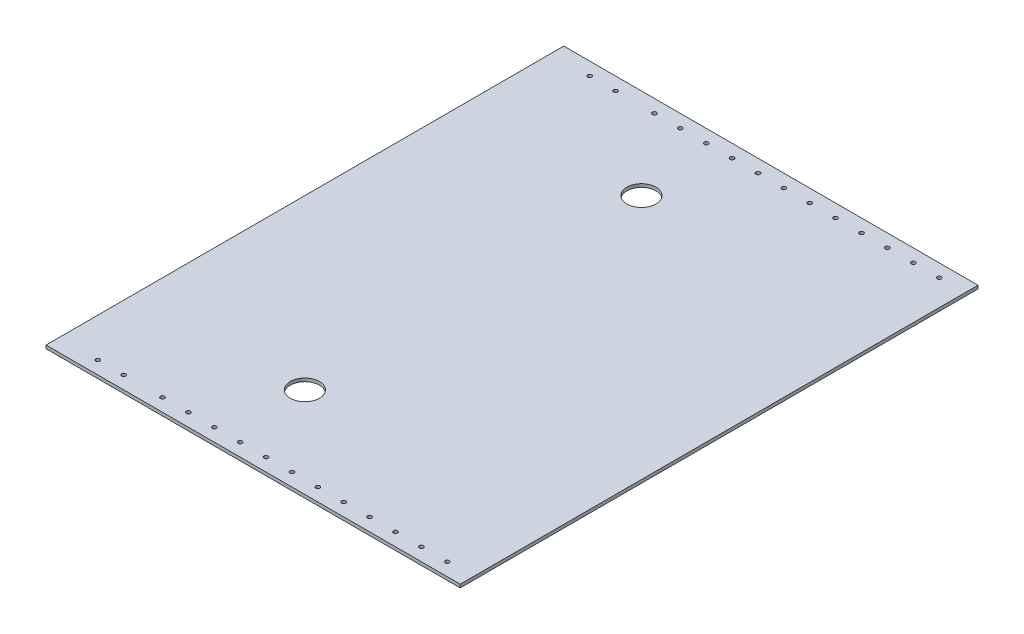
from build123d import *

# Parameters (mm, degrees)
SKETCH1_W               = 571.5
SKETCH1_H               = 508
BOSS_EXTRUDE1_DEPTH     = 3.175
SKETCH2_R               = 14.2875
CUT_EXTRUDE1_DEPTH      = 3.175
SKETCH4_R               = 2.0193
CUT_EXTRUDE3_DEPTH      = 1
CUT_EXTRUDE3_DEPTH_BACK = 4.175
SKETCH5_W               = 619.579537293
SKETCH5_H               = 89.035098343
CUT_EXTRUDE4_DEPTH      = 165.1


with BuildPart() as part:
    # Sketch1 → Boss-Extrude1 (new body)
    with BuildSketch(Plane(origin=(0, 0, 0), x_dir=(1, 0, 0), z_dir=(0, 1, 0))):
        with Locations((285.75, 254)):
            Rectangle(SKETCH1_W, SKETCH1_H)
    extrude(amount=BOSS_EXTRUDE1_DEPTH)

    # Sketch2 → Cut-Extrude1 (cut)
    with BuildSketch(Plane(origin=(0, 3.175, 0), x_dir=(1, 0, 0), z_dir=(0, 1, 0))):
        with Locations((330.2, 419.1)):
            Circle(SKETCH2_R)
        with Locations((330.2, 88.9)):
            Circle(SKETCH2_R)
    extrude(amount=-CUT_EXTRUDE1_DEPTH, mode=Mode.SUBTRACT)

    # Sketch4 → Cut-Extrude3 (cut, two sides)
    with BuildSketch(Plane(origin=(0, 3.175, 0), x_dir=(1, 0, 0), z_dir=(0, 1, 0))) as cut_extrude3_sk:
        with Locations((546.1, 495.3)):
            Circle(SKETCH4_R)
        with Locations((520.7, 495.3)):
            Circle(SKETCH4_R)
        with Locations((495.3, 495.3)):
            Circle(SKETCH4_R)
        with Locations((469.9, 495.3)):
            Circle(SKETCH4_R)
        with Locations((444.5, 495.3)):
            Circle(SKETCH4_R)
        with Locations((419.1, 495.3)):
            Circle(SKETCH4_R)
        with Locations((393.7, 495.3)):
            Circle(SKETCH4_R)
        with Locations((368.3, 495.3)):
            Circle(SKETCH4_R)
        with Locations((342.9, 495.3)):
            Circle(SKETCH4_R)
        with Locations((317.5, 495.3)):
            Circle(SKETCH4_R)
        with Locations((292.1, 495.3)):
            Circle(SKETCH4_R)
        with Locations((266.7, 495.3)):
            Circle(SKETCH4_R)
        with Locations((228.6, 495.3)):
            Circle(SKETCH4_R)
        with Locations((203.2, 495.3)):
            Circle(SKETCH4_R)
        with Locations((203.2, 12.7)):
            Circle(SKETCH4_R)
        with Locations((228.6, 12.7)):
            Circle(SKETCH4_R)
        with Locations((266.7, 12.7)):
            Circle(SKETCH4_R)
        with Locations((292.1, 12.7)):
            Circle(SKETCH4_R)
        with Locations((317.5, 12.7)):
            Circle(SKETCH4_R)
        with Locations((342.9, 12.7)):
            Circle(SKETCH4_R)
        with Locations((368.3, 12.7)):
            Circle(SKETCH4_R)
        with Locations((393.7, 12.7)):
            Circle(SKETCH4_R)
        with Locations((419.1, 12.7)):
            Circle(SKETCH4_R)
        with Locations((444.5, 12.7)):
            Circle(SKETCH4_R)
        with Locations((469.9, 12.7)):
            Circle(SKETCH4_R)
        with Locations((495.3, 12.7)):
            Circle(SKETCH4_R)
        with Locations((520.7, 12.7)):
            Circle(SKETCH4_R)
        with Locations((546.1, 12.7)):
            Circle(SKETCH4_R)
    extrude(amount=CUT_EXTRUDE3_DEPTH, mode=Mode.SUBTRACT)
    extrude(cut_extrude3_sk.sketch, amount=-CUT_EXTRUDE3_DEPTH_BACK, mode=Mode.SUBTRACT)

    # Sketch5 → Cut-Extrude4 (cut)
    with BuildSketch(Plane.ZY):
        with Locations((-257.641209254, 26.710529503)):
            Rectangle(SKETCH5_W, SKETCH5_H)
    extrude(amount=-CUT_EXTRUDE4_DEPTH, mode=Mode.SUBTRACT)


solid = part.part
